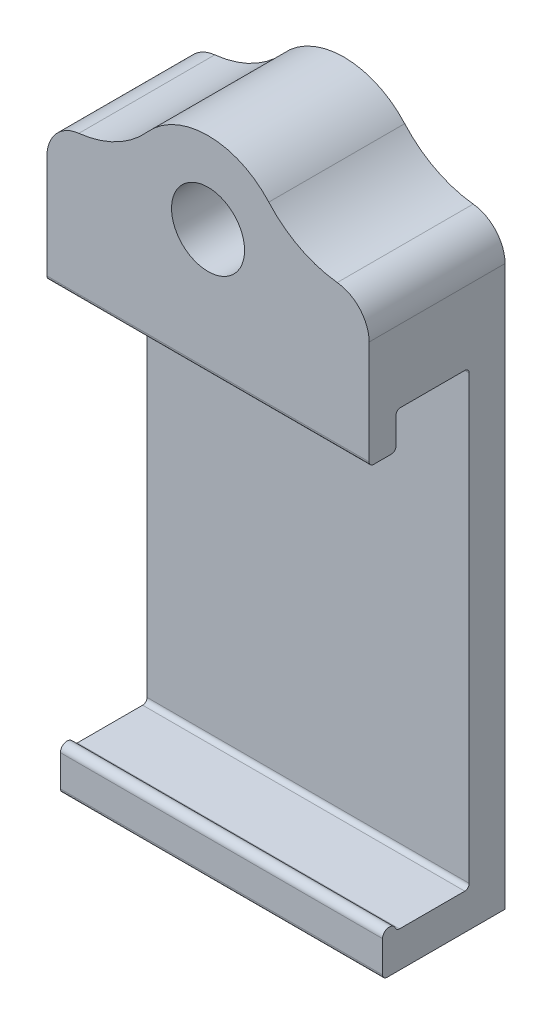
from build123d import *

# Parameters (mm, degrees)
BOSS_EXTRUDE1_DEPTH     = 14.2875
SKETCH3_W               = 28.575
SKETCH3_H               = 12.05625
BOSS_EXTRUDE2_DEPTH     = 12.7
SKETCH4_R               = 3.2385
CUT_EXTRUDE1_DEPTH      = 13.05625
FILLET1_R               = 0.396875
CUT_EXTRUDE2_DEPTH      = 1
CUT_EXTRUDE2_DEPTH_BACK = 13.05625
FILLET2_R               = 9.525
FILLET3_R               = 3.175


with BuildPart() as part:
    # Sketch2 → Boss-Extrude1 (new body, symmetric)
    with BuildSketch(Plane(origin=(0, 0, 0), x_dir=(0, 0, -1), z_dir=(1, 0, 0))):
        with BuildLine():
            Line((-3.25, 16.825), (-5.63125, 16.825))
            Line((-5.63125, 16.825), (-5.63125, 23.175))
            Line((-5.63125, 23.175), (6.425, 23.175))
            Line((6.425, 23.175), (6.425, -23.175))
            Line((6.425, -23.175), (-4.440625, -23.175))
            Line((-4.440625, -23.175), (-4.440625, -20))
            ThreePointArc((-4.440625, -20), (-3.8453125, -19.4046875), (-3.25, -20))
            Line((-3.25, -20), (3.25, -20))
            Line((3.25, -20), (3.25, 20))
            Line((3.25, 20), (-3.25, 20))
            Line((-3.25, 20), (-3.25, 16.825))
        make_face()
    extrude(amount=BOSS_EXTRUDE1_DEPTH, both=True)

    # Sketch3 → Boss-Extrude2 (add)
    with BuildSketch(Plane(origin=(0, 23.175, 0), x_dir=(1, 0, 0), z_dir=(0, 1, 0))):
        with Locations((0, 0.396875)):
            Rectangle(SKETCH3_W, SKETCH3_H)
    extrude(amount=BOSS_EXTRUDE2_DEPTH)

    # Sketch4 → Cut-Extrude1 (cut, through all)
    with BuildSketch(Plane.XY.offset(5.63125)):
        with Locations((0, 27.9375)):
            Circle(SKETCH4_R)
    extrude(amount=-CUT_EXTRUDE1_DEPTH, mode=Mode.SUBTRACT)

    # Fillet1
    fillet1_edges = [part.edges().sort_by_distance(p)[0] for p in [
        (0, 20, -3.25),
        (0, 20, 3.25),
        (0, 16.825, 3.25),
        (0, 16.825, 5.63125),
        (0, -23.175, 4.440625),
        (0, -20, 3.25),
        (0, -20, -3.25),
    ]]
    fillet(fillet1_edges, radius=FILLET1_R)

    # Sketch6 → Cut-Extrude2 (cut, two sides)
    with BuildSketch(Plane.XY.offset(5.63125)) as cut_extrude2_sk:
        with BuildLine():
            Line((-14.2875, 29.525), (-7.030241554, 29.525))
            ThreePointArc((-7.030241554, 29.525), (0, 35.14475), (7.030241554, 29.525))
            Line((7.030241554, 29.525), (14.2875, 29.525))
            Line((14.2875, 29.525), (14.2875, 35.875))
            Line((14.2875, 35.875), (-14.2875, 35.875))
            Line((-14.2875, 35.875), (-14.2875, 29.525))
        make_face()
    extrude(amount=CUT_EXTRUDE2_DEPTH, mode=Mode.SUBTRACT)
    extrude(cut_extrude2_sk.sketch, amount=-CUT_EXTRUDE2_DEPTH_BACK, mode=Mode.SUBTRACT)

    # Fillet2
    fillet2_edges = [part.edges().sort_by_distance(p)[0] for p in [
        (7.030241554, 29.525, -0.396875),
        (-7.030241554, 29.525, -0.396875),
    ]]
    fillet(fillet2_edges, radius=FILLET2_R)

    # Fillet3
    fillet3_edges = [part.edges().sort_by_distance(p)[0] for p in [
        (14.2875, 29.525, -0.396875),
        (-14.2875, 29.525, -0.396875),
    ]]
    fillet(fillet3_edges, radius=FILLET3_R)


solid = part.part
